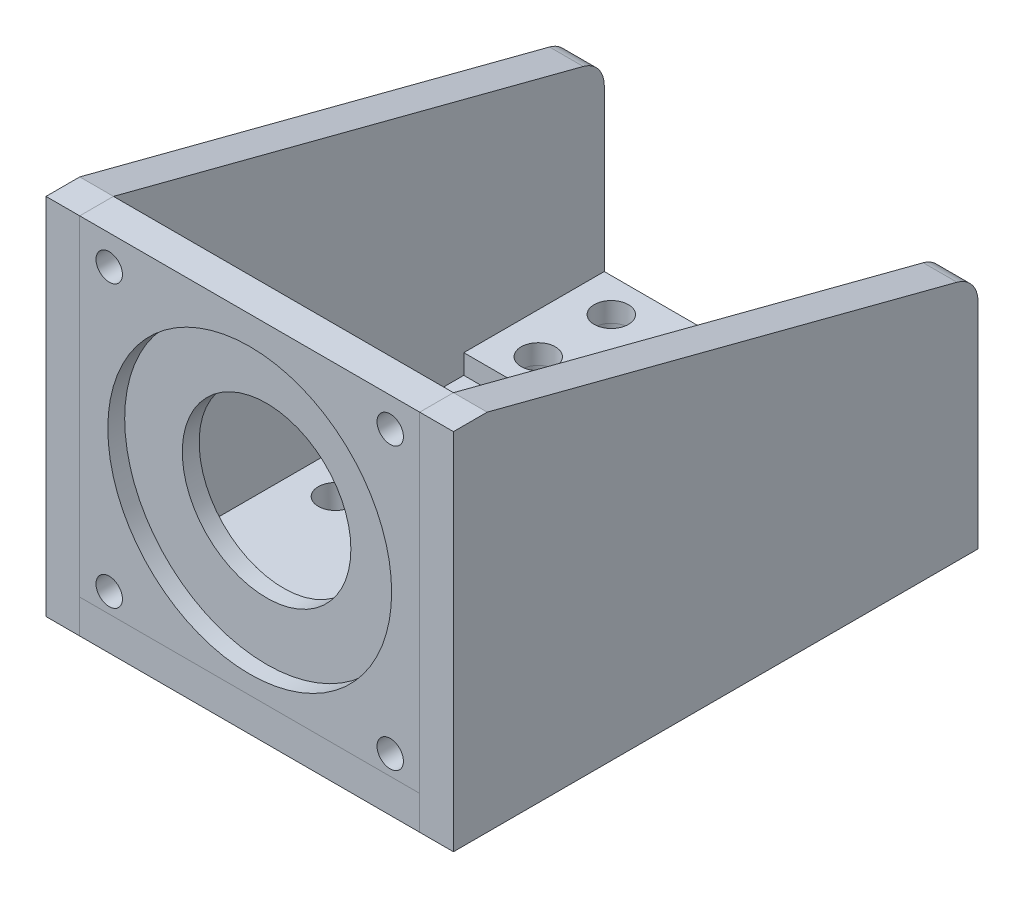
from build123d import *

# Parameters (mm, degrees)
SKETCH1_W                = 60.5
SKETCH1_H                = 60.5
SKETCH1_R                = 15
SKETCH1_R_2              = 2.35
BOSS_EXTRUDE1_DEPTH      = 6
SKETCH2_R                = 25.25
CUT_EXTRUDE1_DEPTH       = 3
SKETCH3_W                = 60.5
SKETCH3_H                = 6
BOSS_EXTRUDE2_DEPTH      = 4.25
SKETCH4_W                = 60.5
SKETCH4_H                = 6
BOSS_EXTRUDE3_DEPTH      = 87.34
BOSS_EXTRUDE4_DEPTH      = 6
SKETCH6_W                = 60.5
SKETCH6_H                = 25
BOSS_EXTRUDE5_DEPTH      = 3.5
CUT_EXTRUDE2_DEPTH       = 115.363370884
CUT_EXTRUDE2_DEPTH_BACK  = 115.363370884
SKETCH7_R                = 3.05
FILLET1_R                = 5
SPLIT1_SURFACE_1_1_BACK  = 135.763
SPLIT1_SURFACE_1_1_DEPTH = 271.526
SPLIT1_SURFACE_1_2_BACK  = 135.763
SPLIT1_SURFACE_1_2_DEPTH = 271.526
SPLIT1_SURFACE_2_3_BACK  = 135.763
SPLIT1_SURFACE_2_3_DEPTH = 271.526
SPLIT1_SURFACE_2_4_BACK  = 135.763
SPLIT1_SURFACE_2_4_DEPTH = 271.526
SPLIT2_SURFACE_5_BACK    = 135.763
SPLIT2_SURFACE_5_DEPTH   = 271.526
SPLIT2_SURFACE_6_BACK    = 135.763
SPLIT2_SURFACE_6_DEPTH   = 271.526


with BuildPart() as part:
    # Sketch1 → Boss-Extrude1 (new body)
    with BuildSketch(Plane.XY):
        Rectangle(SKETCH1_W, SKETCH1_H)
        Circle(SKETCH1_R, mode=Mode.SUBTRACT)
        with Locations((-25, 25)):
            Circle(SKETCH1_R_2, mode=Mode.SUBTRACT)
        with Locations((25, 25)):
            Circle(SKETCH1_R_2, mode=Mode.SUBTRACT)
        with Locations((25, -25)):
            Circle(SKETCH1_R_2, mode=Mode.SUBTRACT)
        with Locations((-25, -25)):
            Circle(SKETCH1_R_2, mode=Mode.SUBTRACT)
    extrude(amount=-BOSS_EXTRUDE1_DEPTH)

    # Sketch2 → Cut-Extrude1 (cut)
    with BuildSketch(Plane.XY):
        Circle(SKETCH2_R)
    extrude(amount=-CUT_EXTRUDE1_DEPTH, mode=Mode.SUBTRACT)

    # Sketch3 → Boss-Extrude2 (add)
    with BuildSketch(Plane.XZ.offset(30.25)):
        with Locations((0, -3)):
            Rectangle(SKETCH3_W, SKETCH3_H)
    extrude(amount=BOSS_EXTRUDE2_DEPTH)

    # Sketch4 → Boss-Extrude3 (add)
    with BuildSketch(Plane(origin=(0, 0, -6), x_dir=(-1, 0, 0), z_dir=(0, 0, -1))):
        with Locations((0, -31.5)):
            Rectangle(SKETCH4_W, SKETCH4_H)
    extrude(amount=BOSS_EXTRUDE3_DEPTH)

    # Sketch5 → Boss-Extrude4 (add)
    with BuildSketch(Plane(origin=(30.25, 0, 0), x_dir=(0, 0, -1), z_dir=(1, 0, 0))):
        Polygon((0, 30.25), (6, 30.25), (93.34, 7.5), (93.34, -34.5), (0, -34.5), align=None)
    boss_extrude4 = extrude(amount=BOSS_EXTRUDE4_DEPTH)

    # Mirror1: Boss-Extrude4 across plane
    add(boss_extrude4.mirror(Plane(origin=(0, 0, 0), x_dir=(0, 0, 1), z_dir=(1, 0, 0))))

    # Sketch6 → Boss-Extrude5 (add)
    with BuildSketch(Plane(origin=(0, -28.5, 0), x_dir=(1, 0, 0), z_dir=(0, 1, 0))):
        with Locations((0, 80.84)):
            Rectangle(SKETCH6_W, SKETCH6_H)
    extrude(amount=BOSS_EXTRUDE5_DEPTH)

    # Sketch7 → Cut-Extrude2 (cut, two sides: drawn at the far end of the back side and taken through both)
    with BuildSketch(Plane(origin=(0, -25, 0), x_dir=(1, 0, 0), z_dir=(0, 1, 0)).offset(-CUT_EXTRUDE2_DEPTH_BACK)):
        with Locations(Location((-23, 87.34, 0), (0, 0, 270))):
            Circle(SKETCH7_R)
        with Locations(Location((23, 87.34, 0), (0, 0, 270))):
            Circle(SKETCH7_R)
        with Locations(Location((23, 74.34, 0), (0, 0, 270))):
            Circle(SKETCH7_R)
        with Locations(Location((-23, 74.34, 0), (0, 0, 270))):
            Circle(SKETCH7_R)
        with Locations(Location((-23, 13.25, 0), (0, 0, 270))):
            Circle(SKETCH7_R)
        with Locations(Location((23, 13.25, 0), (0, 0, 270))):
            Circle(SKETCH7_R)
        with Locations(Location((-23, 38.25, 0), (0, 0, 270))):
            Circle(SKETCH7_R)
        with Locations(Location((23, 38.25, 0), (0, 0, 270))):
            Circle(SKETCH7_R)
    extrude(amount=CUT_EXTRUDE2_DEPTH + CUT_EXTRUDE2_DEPTH_BACK, mode=Mode.SUBTRACT)

    # Fillet1
    fillet1_edges = [part.edges().sort_by_distance(p)[0] for p in [
        (33.25, 7.5, -93.34),
        (-33.25, 7.5, -93.34),
    ]]
    fillet(fillet1_edges, radius=FILLET1_R)


with BuildPart() as body_2:
    # Split1: the piece behind the surface
    add(part.part)
    # Split1 surface 1: a surface, the sketch's curves swept straight by 271.526 mm
    with BuildLine(Plane(origin=(0, 30.25, 0), x_dir=(1, 0, 0), z_dir=(0, 1, 0)).offset(-SPLIT1_SURFACE_1_1_BACK), mode=Mode.PRIVATE) as split1_surface_1_1_path:
        Line((-30.25, 93.34), (-30.25, 0))
    split1_surface_1_1 = Shell.extrude(split1_surface_1_1_path.wire(), (0 * SPLIT1_SURFACE_1_1_DEPTH, 1 * SPLIT1_SURFACE_1_1_DEPTH, 0 * SPLIT1_SURFACE_1_1_DEPTH))
    split(bisect_by=split1_surface_1_1, keep=Keep.BOTTOM)


with BuildPart() as part_1:
    add(part.part)

    # Split1: split by a surface, the side it looks to stays
    # Split1 surface 1: a surface, the sketch's curves swept straight by 271.526 mm
    with BuildLine(Plane(origin=(0, 30.25, 0), x_dir=(1, 0, 0), z_dir=(0, 1, 0)).offset(-SPLIT1_SURFACE_1_2_BACK), mode=Mode.PRIVATE) as split1_surface_1_2_path:
        Line((-30.25, 93.34), (-30.25, 0))
    split1_surface_1_2 = Shell.extrude(split1_surface_1_2_path.wire(), (0 * SPLIT1_SURFACE_1_2_DEPTH, 1 * SPLIT1_SURFACE_1_2_DEPTH, 0 * SPLIT1_SURFACE_1_2_DEPTH))
    split(bisect_by=split1_surface_1_2, keep=Keep.TOP)


with BuildPart() as body_3:
    # Split1 2: the piece behind the surface
    add(part_1.part)
    # Split1 surface 2: a surface, the sketch's curves swept straight by 271.526 mm
    with BuildLine(Plane(origin=(0, 30.25, 0), x_dir=(1, 0, 0), z_dir=(0, 1, 0)).offset(-SPLIT1_SURFACE_2_3_BACK), mode=Mode.PRIVATE) as split1_surface_2_3_path:
        Line((30.25, 93.34), (30.25, 0))
    split1_surface_2_3 = Shell.extrude(split1_surface_2_3_path.wire(), (0 * SPLIT1_SURFACE_2_3_DEPTH, 1 * SPLIT1_SURFACE_2_3_DEPTH, 0 * SPLIT1_SURFACE_2_3_DEPTH))
    split(bisect_by=split1_surface_2_3, keep=Keep.BOTTOM)


with BuildPart() as part_2:
    add(part_1.part)

    # Split1 2: split by a surface, the side it looks to stays
    # Split1 surface 2: a surface, the sketch's curves swept straight by 271.526 mm
    with BuildLine(Plane(origin=(0, 30.25, 0), x_dir=(1, 0, 0), z_dir=(0, 1, 0)).offset(-SPLIT1_SURFACE_2_4_BACK), mode=Mode.PRIVATE) as split1_surface_2_4_path:
        Line((30.25, 93.34), (30.25, 0))
    split1_surface_2_4 = Shell.extrude(split1_surface_2_4_path.wire(), (0 * SPLIT1_SURFACE_2_4_DEPTH, 1 * SPLIT1_SURFACE_2_4_DEPTH, 0 * SPLIT1_SURFACE_2_4_DEPTH))
    split(bisect_by=split1_surface_2_4, keep=Keep.TOP)


with BuildPart() as body_4_2:
    # Split2: the piece behind the surface
    add(body_3.part)
    # Split2 surface: a surface, the sketch's curves swept straight by 271.526 mm
    with BuildLine(Plane(origin=(30.25, 0, 0), x_dir=(0, 0, -1), z_dir=(1, 0, 0)).offset(-SPLIT2_SURFACE_5_BACK), mode=Mode.PRIVATE) as split2_surface_5_path:
        Line((0, -28.5), (93.34, -28.5))
    split2_surface_5 = Shell.extrude(split2_surface_5_path.wire(), (1 * SPLIT2_SURFACE_5_DEPTH, 0 * SPLIT2_SURFACE_5_DEPTH, 0 * SPLIT2_SURFACE_5_DEPTH))
    split(bisect_by=split2_surface_5, keep=Keep.BOTTOM)


with BuildPart() as body_3_1:
    add(body_3.part)

    # Split2: split by a surface, the side it looks to stays
    # Split2 surface: a surface, the sketch's curves swept straight by 271.526 mm
    with BuildLine(Plane(origin=(30.25, 0, 0), x_dir=(0, 0, -1), z_dir=(1, 0, 0)).offset(-SPLIT2_SURFACE_6_BACK), mode=Mode.PRIVATE) as split2_surface_6_path:
        Line((0, -28.5), (93.34, -28.5))
    split2_surface_6 = Shell.extrude(split2_surface_6_path.wire(), (1 * SPLIT2_SURFACE_6_DEPTH, 0 * SPLIT2_SURFACE_6_DEPTH, 0 * SPLIT2_SURFACE_6_DEPTH))
    split(bisect_by=split2_surface_6, keep=Keep.TOP)


solid = Compound([body_2.part, part_2.part, body_4_2.part, body_3_1.part])
